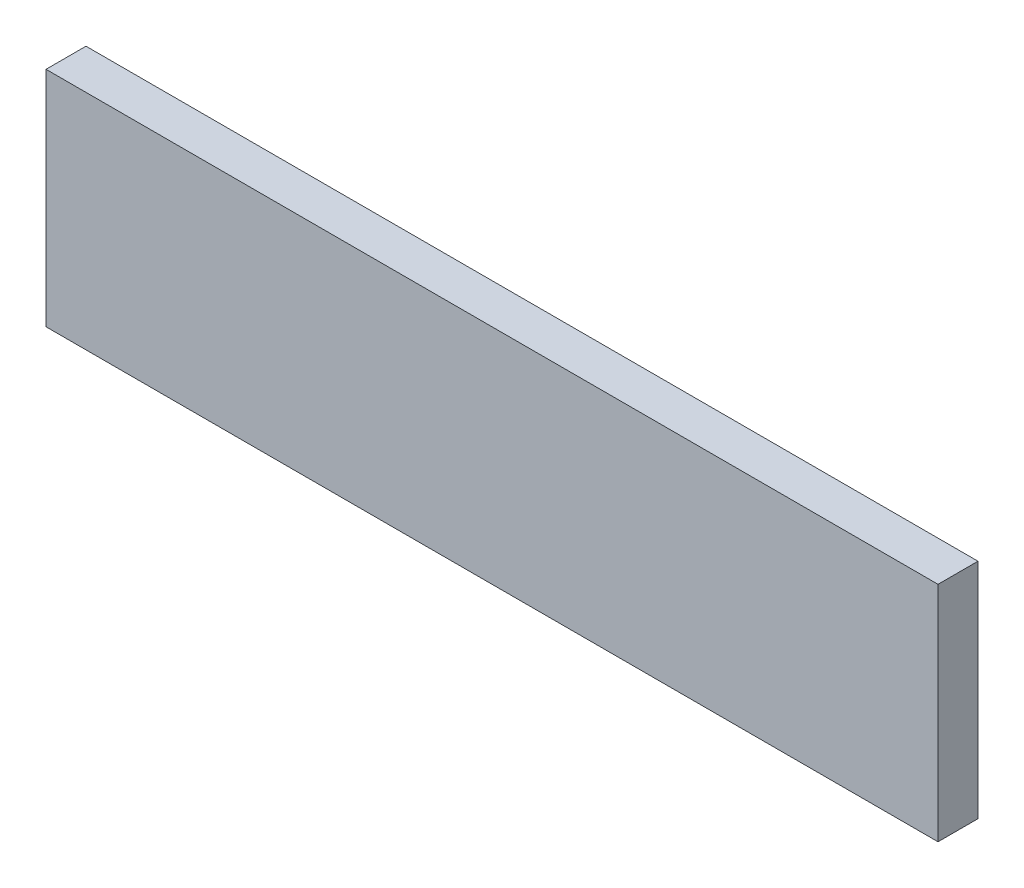
from build123d import *

# Parameters (mm, degrees)
SKETCH3_W           = 68
SKETCH3_H           = 17
BOSS_EXTRUDE1_DEPTH = 3.048


with BuildPart() as part:
    # Sketch3 → Boss-Extrude1 (new body)
    with BuildSketch(Plane.XY):
        Rectangle(SKETCH3_W, SKETCH3_H)
    extrude(amount=BOSS_EXTRUDE1_DEPTH)


solid = part.part
